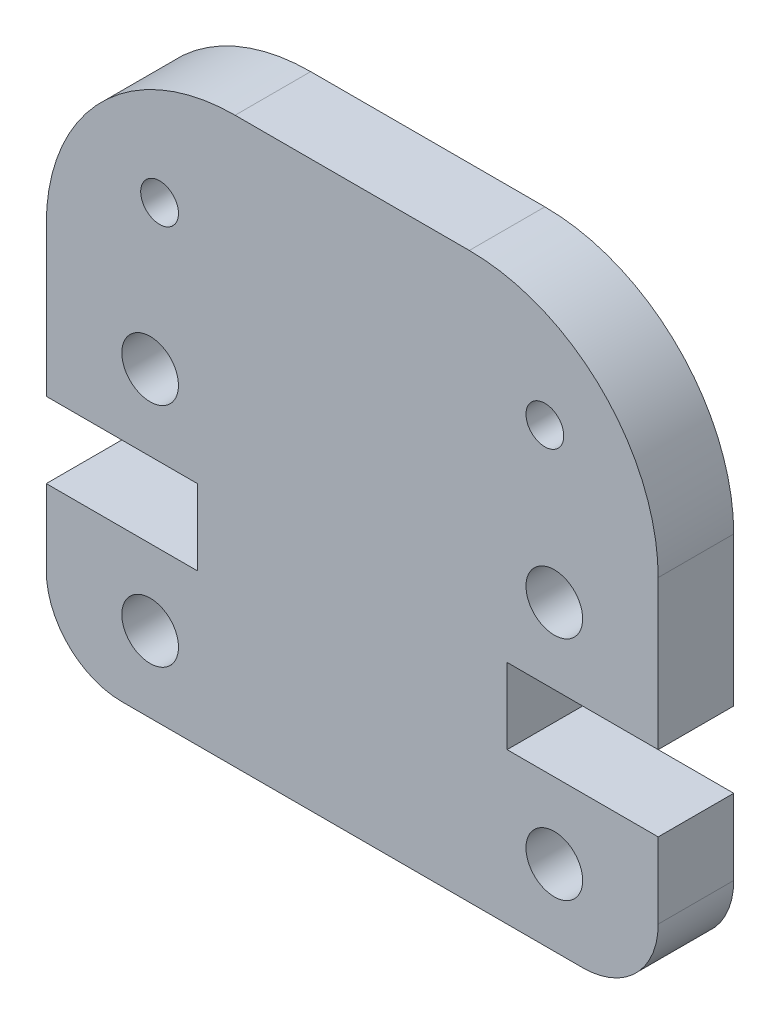
from build123d import *

# Parameters (mm, degrees)
SKETCH2_R           = 0.75
SKETCH2_R_2         = 0.5
BOSS_EXTRUDE1_DEPTH = 2


with BuildPart() as part:
    # Sketch2 → Boss-Extrude1 (new body)
    with BuildSketch(Plane.XY):
        with BuildLine():
            Line((0, 9.945), (0, 6))
            Line((0, 6), (4, 6))
            Line((4, 6), (4, 4))
            Line((4, 4), (0, 4))
            Line((0, 4), (0, 2))
            ThreePointArc((0, 2), (0.585786438, 0.585786438), (2, 0))
            Line((2, 0), (14.2, 0))
            ThreePointArc((14.2, 0), (15.614213562, 0.585786438), (16.2, 2))
            Line((16.2, 2), (16.2, 4))
            Line((16.2, 4), (12.2, 4))
            Line((12.2, 4), (12.2, 6))
            Line((12.2, 6), (16.2, 6))
            Line((16.2, 6), (16.2, 9.945))
            ThreePointArc((16.2, 9.945), (14.735533906, 13.480533906), (11.2, 14.945))
            Line((11.2, 14.945), (5, 14.945))
            ThreePointArc((5, 14.945), (1.464466094, 13.480533906), (0, 9.945))
        make_face()
        with Locations((13.45, 8)):
            Circle(SKETCH2_R, mode=Mode.SUBTRACT)
        with Locations((13.45, 2)):
            Circle(SKETCH2_R, mode=Mode.SUBTRACT)
        with Locations((13.2, 11.942)):
            Circle(SKETCH2_R_2, mode=Mode.SUBTRACT)
        with Locations((3, 11.942)):
            Circle(SKETCH2_R_2, mode=Mode.SUBTRACT)
        with Locations((2.75, 2)):
            Circle(SKETCH2_R, mode=Mode.SUBTRACT)
        with Locations((2.75, 8)):
            Circle(SKETCH2_R, mode=Mode.SUBTRACT)
    extrude(amount=BOSS_EXTRUDE1_DEPTH)


solid = part.part
